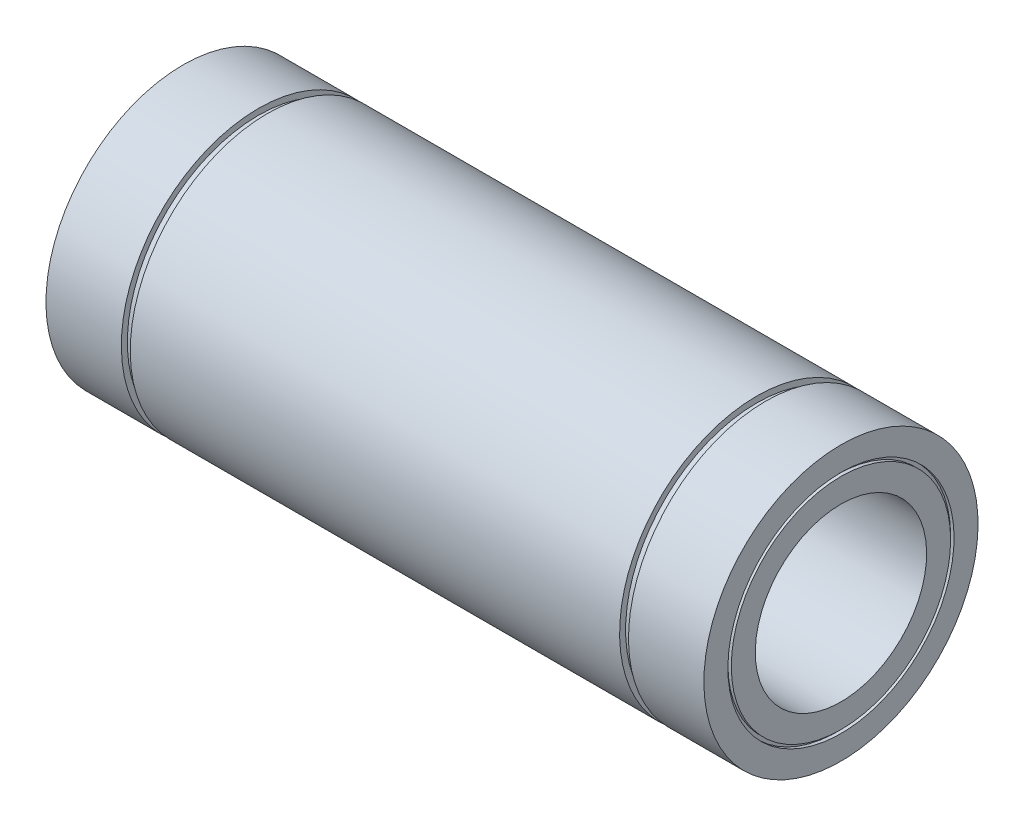
from build123d import *


with BuildPart() as part:
    # Esboço1 → Revolução1 (revolve)
    with BuildSketch(Plane.XY):
        Polygon((-96, 40), (-74, 40), (-74, 38.25), (-71.4, 38.25), (-71.4, 40), (71.4, 40), (71.4, 38.25), (74, 38.25), (74, 40), (96, 40), (96, 33), (95, 33), (95, 32), (96, 32), (96, 25), (-96, 25), (-96, 32), (-95, 32), (-95, 33), (-96, 33), align=None)
    revolve(axis=Axis((0, 0, 0), (-1, 0, 0)))


solid = part.part
